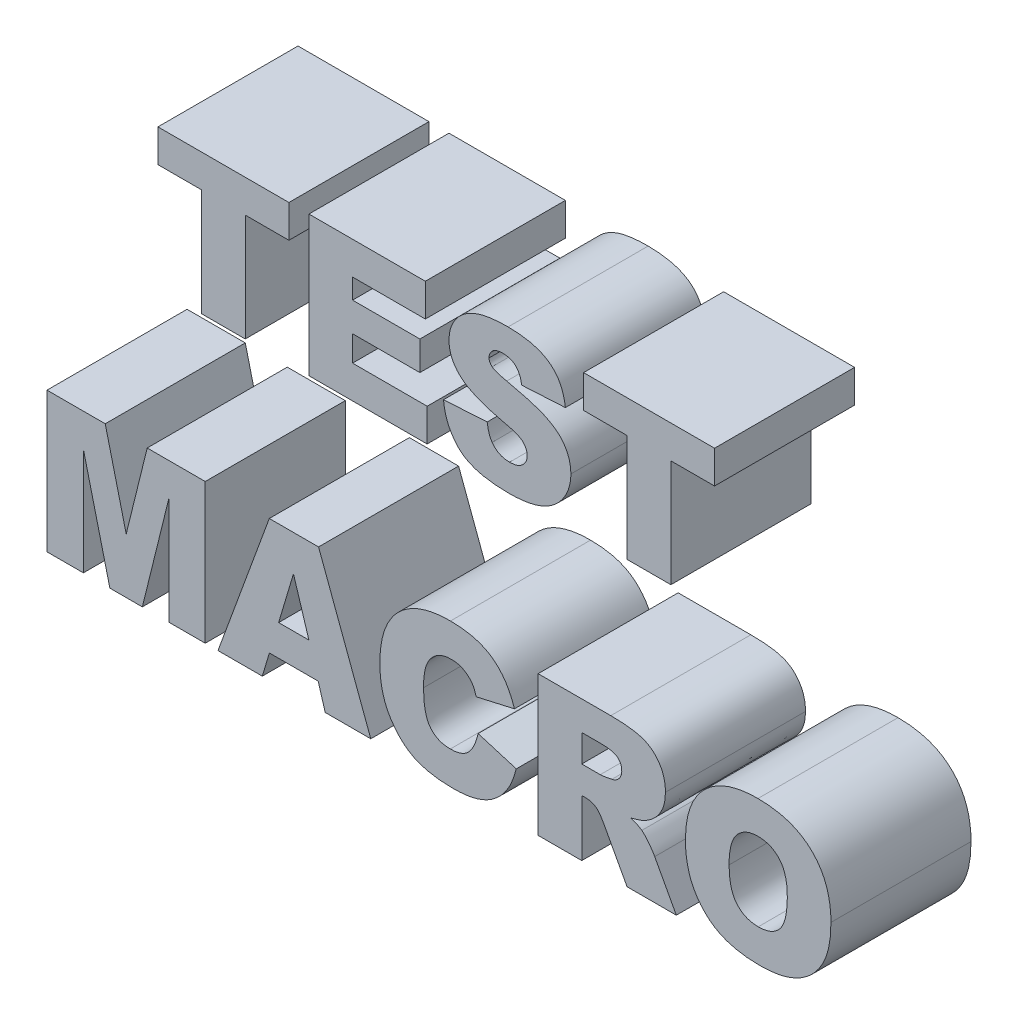
from build123d import *

# Parameters (mm, degrees)
BOSS_EXTRU_1_DEPTH   = 20
BOSS_EXTRU_1_2_DEPTH = 20
BOSS_EXTRU_1_3_DEPTH = 20
BOSS_EXTRU_1_4_DEPTH = 20
BOSS_EXTRU_1_5_DEPTH = 20
BOSS_EXTRU_1_6_DEPTH = 20
BOSS_EXTRU_1_7_DEPTH = 20
BOSS_EXTRU_1_8_DEPTH = 20
BOSS_EXTRU_1_9_DEPTH = 20


with BuildPart() as part:
    # Esquisse1 → Boss.-Extru.1 (new body)
    with BuildSketch(Plane.XY):
        Polygon((-39.74025974, 20), (-21.038961039, 20), (-21.038961039, 15.324675325), (-27.272727273, 15.324675325), (-27.272727273, 0), (-33.506493506, 0), (-33.506493506, 15.324675325), (-39.74025974, 15.324675325), align=None)
    extrude(amount=BOSS_EXTRU_1_DEPTH)


with BuildPart() as body_2:
    # Esquisse1 → Boss.-Extru.1 2 (new body)
    with BuildSketch(Plane.XY):
        Polygon((-18.181818182, 20), (-1.558441558, 20), (-1.558441558, 15.324675325), (-11.948051948, 15.324675325), (-11.948051948, 12.467532468), (-2.337662338, 12.467532468), (-2.337662338, 8.311688312), (-11.948051948, 8.311688312), (-11.948051948, 4.675324675), (-1.298701299, 4.675324675), (-1.298701299, 0), (-18.181818182, 0), align=None)
    extrude(amount=BOSS_EXTRU_1_2_DEPTH)


with BuildPart() as body_3:
    # Esquisse1 → Boss.-Extru.1 3 (new body)
    with BuildSketch(Plane.XY):
        with BuildLine():
            Line((1.038961039, 6.647727273), (7.272727273, 7.012987013))
            add(Edge.make_bspline(
                [(7.272727273, 7.012987013), (7.304757488, 6.788890935), (7.365318812, 6.365179916), (7.520102948, 5.775721889), (7.715213941, 5.266442228), (7.897409487, 4.977422352), (7.982954545, 4.841720779)],
                knots=[0, 0, 0, 0, 1.177086864, 2.225584133, 3.166870363, 4, 4, 4, 4], degree=3))
            add(Edge.make_bspline(
                [(7.982954545, 4.841720779), (8.057748183, 4.745013581), (8.204026944, 4.55587705), (8.460115533, 4.309854222), (8.737918662, 4.100984335), (9.038994512, 3.929550021), (9.364258811, 3.798854044), (9.711720263, 3.706001839), (10.083305918, 3.648068474), (10.339339805, 3.640334173), (10.470779221, 3.636363636)],
                knots=[0, 0, 0, 0, 1.018395363, 1.991741784, 2.950663557, 3.910580234, 4.872152798, 5.865559653, 6.904248207, 8, 8, 8, 8], degree=3))
            add(Edge.make_bspline(
                [(10.470779221, 3.636363636), (10.660697178, 3.644207006), (11.022625097, 3.659154168), (11.533809901, 3.769484502), (11.973966232, 3.967441181), (12.340863101, 4.236798571), (12.620513949, 4.563886639), (12.837407106, 4.912793324), (12.963617859, 5.29468435), (12.979194665, 5.557847844), (12.987012987, 5.689935065)],
                knots=[0, 0, 0, 0, 1.255494896, 2.392604995, 3.433462242, 4.424586182, 5.375455995, 6.262142744, 7.127733362, 8, 8, 8, 8], degree=3))
            add(Edge.make_bspline(
                [(12.987012987, 5.689935065), (12.979878177, 5.816517585), (12.965736379, 6.067414854), (12.854878841, 6.431888084), (12.674125852, 6.77522457), (12.505409594, 6.97526787), (12.418831169, 7.077922078)],
                knots=[0, 0, 0, 0, 0.988314839, 1.958923673, 2.95260139, 4, 4, 4, 4], degree=3))
            add(Edge.make_bspline(
                [(12.418831169, 7.077922078), (12.363439884, 7.129790582), (12.240799231, 7.244631523), (12.003357878, 7.390373942), (11.710911221, 7.540678866), (11.35684867, 7.684129653), (10.944336218, 7.825116295), (10.473595352, 7.967349697), (9.940841737, 8.10371271), (9.564606885, 8.189495991), (9.366883117, 8.234577922)],
                knots=[0, 0, 0, 0, 0.55123045, 1.220467485, 2.017678126, 2.944918583, 3.99760765, 5.190855943, 6.523702564, 8, 8, 8, 8], degree=3))
            add(Edge.make_bspline(
                [(9.366883117, 8.234577922), (9.038755531, 8.310107225), (8.405080772, 8.455968211), (7.497896672, 8.715197767), (6.661730047, 8.98259304), (5.899095569, 9.275803812), (5.208846498, 9.586729824), (4.590906008, 9.914158894), (4.043015356, 10.257363012), (3.722047871, 10.516400681), (3.56737013, 10.641233766)],
                knots=[0, 0, 0, 0, 1.27526578, 2.462772933, 3.57286582, 4.599737504, 5.556111329, 6.438742692, 7.247613029, 8, 8, 8, 8], degree=3))
            add(Edge.make_bspline(
                [(3.56737013, 10.641233766), (3.427977592, 10.768351486), (3.153824483, 11.018362847), (2.79600712, 11.435004806), (2.491087609, 11.87585656), (2.24897906, 12.345217097), (2.054206783, 12.838127189), (1.91786419, 13.35708603), (1.83454926, 13.90288953), (1.823712326, 14.274591676), (1.818181818, 14.464285714)],
                knots=[0, 0, 0, 0, 1.041173921, 2.047749992, 3.025972441, 3.99516429, 4.95811478, 5.947685897, 6.952624423, 8, 8, 8, 8], degree=3))
            add(Edge.make_bspline(
                [(1.818181818, 14.464285714), (1.829440042, 14.715442956), (1.851959923, 15.217834042), (2.02443191, 15.957122705), (2.306111483, 16.672945441), (2.62558045, 17.243912502), (2.933739677, 17.68260842), (3.198757164, 17.996149923), (3.493277568, 18.289221073), (3.814866517, 18.565787518), (4.163552599, 18.824505998), (4.539160907, 19.067030798), (4.946029313, 19.282685268), (5.378756053, 19.489381732), (5.847595304, 19.672349396), (6.356395013, 19.82973168), (6.906699601, 19.963584625), (7.497701456, 20.071314884), (8.130126213, 20.156728846), (8.803181667, 20.216124972), (9.517977912, 20.253257532), (10.008069294, 20.257540749), (10.25974026, 20.25974026)],
                knots=[0, 0, 0, 0, 1.30907172, 2.618542707, 3.936691428, 5.31077926, 6.019465884, 6.730466994, 7.448921369, 8.184394082, 8.940790577, 9.711951077, 10.513842775, 11.340797704, 12.212135637, 13.136052958, 14.116643754, 15.164270918, 16.267925536, 17.44397513, 18.687434074, 20, 20, 20, 20], degree=3))
            add(Edge.make_bspline(
                [(10.25974026, 20.25974026), (10.568342802, 20.256941234), (11.166092343, 20.251519646), (12.034296107, 20.178603689), (12.846609378, 20.072531329), (13.602815531, 19.920390908), (14.300635089, 19.719423531), (14.946063298, 19.484031066), (15.531678257, 19.193535604), (16.066217055, 18.864457954), (16.545763364, 18.483061279), (16.975028198, 18.051046223), (17.349291106, 17.564576082), (17.67319508, 17.026717817), (17.943001271, 16.436159553), (18.167136755, 15.795393237), (18.338927282, 15.10235266), (18.406710328, 14.619290084), (18.441558442, 14.370941558)],
                knots=[0, 0, 0, 0, 1.311515668, 2.540348123, 3.700957581, 4.792716183, 5.815693949, 6.78561682, 7.708932939, 8.58979416, 9.449314928, 10.307353016, 11.17237775, 12.052130674, 12.970724468, 13.927412188, 14.934456625, 16, 16, 16, 16], degree=3))
            Line((18.441558442, 14.370941558), (12.207792208, 14.025974026))
            add(Edge.make_bspline(
                [(12.207792208, 14.025974026), (12.168366471, 14.238211159), (12.094144138, 14.637765774), (11.909520247, 15.188415747), (11.658879014, 15.645051097), (11.345852875, 16.012778297), (10.969483014, 16.291833535), (10.529579913, 16.48869648), (10.025790111, 16.600629888), (9.670482334, 16.615563203), (9.484577922, 16.623376623)],
                knots=[0, 0, 0, 0, 1.234522949, 2.324095391, 3.308461247, 4.197778927, 5.06646789, 5.967370861, 6.936486201, 8, 8, 8, 8], degree=3))
            add(Edge.make_bspline(
                [(9.484577922, 16.623376623), (9.332640126, 16.618594079), (9.046327063, 16.609581806), (8.643949905, 16.525419171), (8.301074326, 16.379458324), (8.019810915, 16.17787747), (7.803687171, 15.935639495), (7.642733592, 15.666844213), (7.552700401, 15.368104926), (7.5392742, 15.161540133), (7.532467532, 15.056818182)],
                knots=[0, 0, 0, 0, 1.295349582, 2.44096936, 3.485284873, 4.452772794, 5.368250369, 6.237362108, 7.106397189, 8, 8, 8, 8], degree=3))
            add(Edge.make_bspline(
                [(7.532467532, 15.056818182), (7.537805846, 14.9788347), (7.548530011, 14.822173281), (7.642276312, 14.596708316), (7.784898824, 14.38170238), (7.91764903, 14.262678671), (7.987012987, 14.200487013)],
                knots=[0, 0, 0, 0, 0.931359322, 1.871012551, 2.887572404, 4, 4, 4, 4], degree=3))
            add(Edge.make_bspline(
                [(7.987012987, 14.200487013), (8.029684325, 14.167153327), (8.122118566, 14.094946216), (8.287506403, 13.99681263), (8.492892242, 13.905598235), (8.733985241, 13.813292624), (9.01350503, 13.724155735), (9.329226445, 13.636226954), (9.681888588, 13.545839835), (9.930782476, 13.49334669), (10.060876623, 13.465909091)],
                knots=[0, 0, 0, 0, 0.58558372, 1.268485821, 2.074195609, 3.01489626, 4.061191977, 5.247631417, 6.561366666, 8, 8, 8, 8], degree=3))
            add(Edge.make_bspline(
                [(10.060876623, 13.465909091), (10.387067838, 13.393586512), (11.015988584, 13.254143239), (11.923542647, 13.040566279), (12.757077273, 12.822446725), (13.518675373, 12.60240291), (14.210259261, 12.385724835), (14.827982673, 12.162549099), (15.377180204, 11.945483152), (15.856898714, 11.719139488), (16.288368969, 11.488494744), (16.681667772, 11.244221761), (17.04748109, 10.9898726), (17.383126712, 10.720726157), (17.687089142, 10.436018445), (17.964347685, 10.140664585), (18.210007715, 9.829671477), (18.493887745, 9.399505856), (18.785318282, 8.831220693), (19.040676871, 8.108589725), (19.194603618, 7.344176044), (19.211968142, 6.820238606), (19.220779221, 6.554383117)],
                knots=[0, 0, 0, 0, 1.592169224, 3.069819826, 4.44270182, 5.69748484, 6.847378755, 7.89551184, 8.826870635, 9.660312258, 10.421783, 11.157070095, 11.86529408, 12.543880036, 13.205252394, 13.848401972, 14.47263075, 15.091275346, 16.302236043, 17.505191012, 18.73408805, 20, 20, 20, 20], degree=3))
            add(Edge.make_bspline(
                [(19.220779221, 6.554383117), (19.217646961, 6.395990945), (19.211447687, 6.082505888), (19.162246953, 5.616825519), (19.07596159, 5.161387963), (18.95804342, 4.71380739), (18.8083259, 4.275334519), (18.623924435, 3.8472749), (18.408607586, 3.42730946), (18.158636428, 3.020450719), (17.877153681, 2.631625875), (17.575426862, 2.259755875), (17.23791471, 1.920264518), (16.882949454, 1.594601112), (16.489702368, 1.307629517), (16.081078883, 1.030409462), (15.638277087, 0.789487484), (15.172913565, 0.563679022), (14.67511286, 0.370970487), (14.150290205, 0.198281994), (13.59226252, 0.058621134), (13.003476069, -0.060367264), (12.382530041, -0.147323407), (11.731323148, -0.211877842), (11.050341943, -0.25416091), (10.58583241, -0.257856336), (10.349025974, -0.25974026)],
                knots=[0, 0, 0, 0, 0.906069916, 1.793266525, 2.675214908, 3.55566777, 4.439244741, 5.323397786, 6.219930383, 7.137170545, 8.052187568, 8.964877591, 9.873423338, 10.788702187, 11.717462046, 12.655527384, 13.611744184, 14.598361818, 15.613055283, 16.663057224, 17.757447019, 18.901923475, 20.098271487, 21.342794296, 22.645359534, 24, 24, 24, 24], degree=3))
            add(Edge.make_bspline(
                [(10.349025974, -0.25974026), (9.938987085, -0.253136013), (9.150347592, -0.240433877), (8.016453658, -0.154700187), (6.982252, 0.000180008), (6.04322188, 0.205183493), (5.203695963, 0.482027844), (4.456483235, 0.811678702), (3.80896829, 1.209064881), (3.261695195, 1.673654588), (2.793442085, 2.182247392), (2.384581172, 2.725367656), (2.017822275, 3.294409019), (1.714772738, 3.902768442), (1.462240866, 4.542339722), (1.262591013, 5.21419737), (1.120595321, 5.919615671), (1.066471538, 6.40235593), (1.038961039, 6.647727273)],
                knots=[0, 0, 0, 0, 1.505803467, 2.896154762, 4.172048974, 5.343508697, 6.421214708, 7.412908531, 8.336567115, 9.200370628, 10.040536338, 10.870193375, 11.694343728, 12.523048299, 13.361626238, 14.216714319, 15.093576323, 16, 16, 16, 16], degree=3))
        make_face()
    extrude(amount=BOSS_EXTRU_1_3_DEPTH)


with BuildPart() as body_4:
    # Esquisse1 → Boss.-Extru.1 4 (new body)
    with BuildSketch(Plane.XY):
        Polygon((21.038961039, 20), (39.74025974, 20), (39.74025974, 15.324675325), (33.506493506, 15.324675325), (33.506493506, 0), (27.272727273, 0), (27.272727273, 15.324675325), (21.038961039, 15.324675325), align=None)
    extrude(amount=BOSS_EXTRU_1_4_DEPTH)


with BuildPart() as body_5:
    # Esquisse1 → Boss.-Extru.1 5 (new body)
    with BuildSketch(Plane.XY):
        Polygon((-55.584415584, -20.480519481), (-47.268668831, -20.480519481), (-44.273538961, -32.619318182), (-41.274350649, -20.480519481), (-32.987012987, -20.480519481), (-32.987012987, -40.480519481), (-38.181818182, -40.480519481), (-38.181818182, -25.168019481), (-41.968344156, -40.480519481), (-46.607142857, -40.480519481), (-50.38961039, -25.168019481), (-50.38961039, -40.480519481), (-55.584415584, -40.480519481), align=None)
    extrude(amount=BOSS_EXTRU_1_5_DEPTH)


with BuildPart() as body_6:
    # Esquisse1 → Boss.-Extru.1 6 (new body)
    with BuildSketch(Plane.XY):
        Polygon((-16.862824675, -37.103896104), (-23.82711039, -37.103896104), (-24.837662338, -40.480519481), (-31.168831169, -40.480519481), (-23.839285714, -20.480519481), (-16.806006494, -20.480519481), (-9.350649351, -40.480519481), (-15.852272727, -40.480519481), align=None)
        Polygon((-18.185876623, -32.688311688), (-20.38961039, -25.594155844), (-22.508116883, -32.688311688), align=None, mode=Mode.SUBTRACT)
    extrude(amount=BOSS_EXTRU_1_6_DEPTH)


with BuildPart() as body_7:
    # Esquisse1 → Boss.-Extru.1 7 (new body)
    with BuildSketch(Plane.XY):
        with BuildLine():
            Line((5.974025974, -32.168831169), (11.428571429, -33.808441558))
            add(Edge.make_bspline(
                [(11.428571429, -33.808441558), (11.381594362, -33.99560524), (11.288774064, -34.365415236), (11.121587416, -34.904251888), (10.937129606, -35.419975314), (10.725445525, -35.909062427), (10.507763121, -36.380598058), (10.256877371, -36.82214894), (9.992893827, -37.243025486), (9.618697229, -37.767891947), (9.099132289, -38.367897894), (8.403349708, -39.00164922), (7.631847889, -39.537594215), (6.933478148, -39.904511208), (6.335543565, -40.147156216), (5.853523203, -40.304357233), (5.344867336, -40.443075678), (4.803704413, -40.552143358), (4.234621495, -40.635981389), (3.634725857, -40.696672874), (3.006421009, -40.733598253), (2.577161587, -40.738007897), (2.357954545, -40.74025974)],
                knots=[0, 0, 0, 0, 0.924244921, 1.826182348, 2.701535968, 3.546520642, 4.378482427, 5.187954248, 5.977251764, 6.757720469, 8.273918964, 9.769591919, 11.254542257, 12.76187881, 13.538084839, 14.343473581, 15.189228286, 16.062372142, 16.986208014, 17.943795036, 18.949971547, 20, 20, 20, 20], degree=3))
            add(Edge.make_bspline(
                [(2.357954545, -40.74025974), (2.091405499, -40.736560624), (1.571528512, -40.729345872), (0.81037975, -40.690137052), (0.086853014, -40.6184521), (-0.599029501, -40.510691529), (-1.250548636, -40.384277359), (-1.862927904, -40.221617649), (-2.437761763, -40.030769844), (-2.978673964, -39.811074509), (-3.493484538, -39.553421284), (-3.982720164, -39.247233538), (-4.45815626, -38.900936829), (-4.910733261, -38.505037026), (-5.350794823, -38.069440668), (-5.774982974, -37.58995615), (-6.173236365, -37.059732254), (-6.561549698, -36.494198062), (-6.914902875, -35.88319584), (-7.220535059, -35.225978334), (-7.474567144, -34.525689779), (-7.684651118, -33.786292865), (-7.852582222, -33.007127393), (-7.968527518, -32.18525913), (-8.037495462, -31.321806784), (-8.047068979, -30.732270845), (-8.051948052, -30.431818182)],
                knots=[0, 0, 0, 0, 1.147650446, 2.238376252, 3.280413316, 4.276323793, 5.226689047, 6.13651372, 7.002182501, 7.832854118, 8.648150377, 9.477309563, 10.314915342, 11.177895551, 12.063382281, 12.979505193, 13.931243744, 14.916675708, 15.931699666, 16.966189071, 18.033078903, 19.13554484, 20.273354093, 21.461953011, 22.706502983, 24, 24, 24, 24], degree=3))
            add(Edge.make_bspline(
                [(-8.051948052, -30.431818182), (-8.045127637, -30.033702385), (-8.031844806, -29.258367586), (-7.900827666, -28.131177473), (-7.703502588, -27.071945005), (-7.415838523, -26.083976506), (-7.040468271, -25.171169768), (-6.589262006, -24.326086781), (-6.049371871, -23.555231015), (-5.43126086, -22.853934719), (-4.735711713, -22.232402228), (-3.970049566, -21.692496225), (-3.135509323, -21.235273882), (-2.232698525, -20.863316896), (-1.2615876, -20.57402325), (-0.223348382, -20.370498446), (0.8828391, -20.241382625), (1.643297667, -20.227763459), (2.033279221, -20.220779221)],
                knots=[0, 0, 0, 0, 1.16882947, 2.276307973, 3.328298317, 4.330369038, 5.292534416, 6.222298076, 7.138273771, 8.050302673, 8.962002626, 9.87147472, 10.796156015, 11.750975379, 12.733998957, 13.767258903, 14.854996341, 16, 16, 16, 16], degree=3))
            add(Edge.make_bspline(
                [(2.033279221, -20.220779221), (2.33915563, -20.225263769), (2.935587602, -20.234008241), (3.80463555, -20.307316386), (4.622940972, -20.429837288), (5.392636217, -20.591540902), (6.109043783, -20.813988319), (6.779816192, -21.0749233), (7.396891332, -21.392981049), (7.968869526, -21.756971), (8.493499483, -22.174802293), (8.984423343, -22.638896706), (9.434864273, -23.160067609), (9.859383323, -23.726491921), (10.239534428, -24.352898573), (10.588368256, -25.026576584), (10.902697676, -25.752294683), (11.078768789, -26.259856743), (11.168831169, -26.519480519)],
                knots=[0, 0, 0, 0, 1.217751659, 2.374508141, 3.469163924, 4.51086882, 5.502490221, 6.452709996, 7.372946509, 8.261977267, 9.147787688, 10.039327766, 10.947855999, 11.887251211, 12.85447837, 13.861487269, 14.906126374, 16, 16, 16, 16], degree=3))
            Line((11.168831169, -26.519480519), (5.714285714, -27.753246753))
            add(Edge.make_bspline(
                [(5.714285714, -27.753246753), (5.668858206, -27.607812612), (5.583941635, -27.335956002), (5.436691359, -26.964938693), (5.290886402, -26.652432483), (5.175004097, -26.47513946), (5.121753247, -26.393668831)],
                knots=[0, 0, 0, 0, 1.227562621, 2.294653845, 3.216350308, 4, 4, 4, 4], degree=3))
            add(Edge.make_bspline(
                [(5.121753247, -26.393668831), (5.033940652, -26.277612381), (4.861176328, -26.049280507), (4.555803565, -25.751855445), (4.225481079, -25.493780994), (3.867229538, -25.278240613), (3.483579991, -25.105654405), (3.075408373, -24.98498723), (2.646197399, -24.909401982), (2.352860428, -24.900585845), (2.203733766, -24.896103896)],
                knots=[0, 0, 0, 0, 1.022346025, 2.011384825, 2.987756405, 3.965193716, 4.94480522, 5.938182432, 6.9518131, 8, 8, 8, 8], degree=3))
            add(Edge.make_bspline(
                [(2.203733766, -24.896103896), (2.035676419, -24.900258937), (1.707159303, -24.908381178), (1.230050481, -24.986982879), (0.782408797, -25.116690392), (0.366094472, -25.301742738), (-0.023407041, -25.533134156), (-0.378953168, -25.820852256), (-0.702298649, -26.160437547), (-0.88764181, -26.417050291), (-0.982142857, -26.54788961)],
                knots=[0, 0, 0, 0, 1.074844658, 2.101097481, 3.084644682, 4.049882427, 5.009082629, 5.975872329, 6.967956603, 8, 8, 8, 8], degree=3))
            add(Edge.make_bspline(
                [(-0.982142857, -26.54788961), (-1.049663799, -26.656070598), (-1.189710868, -26.880451801), (-1.355469296, -27.257128679), (-1.505227707, -27.6721141), (-1.613105213, -28.134807819), (-1.709349176, -28.637887494), (-1.770389013, -29.187406731), (-1.81304989, -29.779080125), (-1.816435026, -30.188224679), (-1.818181818, -30.399350649)],
                knots=[0, 0, 0, 0, 0.765245572, 1.587217177, 2.466349779, 3.412541567, 4.437552015, 5.542455106, 6.731862501, 8, 8, 8, 8], degree=3))
            add(Edge.make_bspline(
                [(-1.818181818, -30.399350649), (-1.814825214, -30.660490254), (-1.808402351, -31.160180961), (-1.766676669, -31.878605152), (-1.684622911, -32.532815731), (-1.577465298, -33.124235791), (-1.442521854, -33.654388989), (-1.267602658, -34.117381784), (-1.067558141, -34.521417882), (-0.826667912, -34.860050154), (-0.559628516, -35.146626957), (-0.268408779, -35.393986876), (0.049417998, -35.599431346), (0.389166806, -35.774130257), (0.758454914, -35.902798294), (1.151685086, -35.994714627), (1.570233085, -36.053423749), (1.857213247, -36.061024388), (2.00487013, -36.064935065)],
                knots=[0, 0, 0, 0, 1.602188715, 3.065788552, 4.412313171, 5.644618019, 6.751844607, 7.7630822, 8.676201586, 9.50981682, 10.302645847, 11.074162151, 11.847640242, 12.619692074, 13.412477657, 14.239872104, 15.094379917, 16, 16, 16, 16], degree=3))
            add(Edge.make_bspline(
                [(2.00487013, -36.064935065), (2.146998792, -36.061466565), (2.423861415, -36.054710026), (2.826689187, -36.012557164), (3.201147249, -35.92994323), (3.548981488, -35.820080839), (3.871765131, -35.683458782), (4.166468548, -35.511879273), (4.433195239, -35.306581732), (4.672752057, -35.068360652), (4.893316179, -34.803568328), (5.091650709, -34.507600587), (5.27832726, -34.186147091), (5.452882131, -33.838830351), (5.608050882, -33.461447212), (5.742680797, -33.056145727), (5.871988025, -32.624061236), (5.939350952, -32.32352962), (5.974025974, -32.168831169)],
                knots=[0, 0, 0, 0, 1.110419556, 2.163065953, 3.158007967, 4.100495665, 5.00938437, 5.890256362, 6.756877028, 7.631195438, 8.524217963, 9.444584223, 10.410653115, 11.426752889, 12.478656378, 13.594843866, 14.761947466, 16, 16, 16, 16], degree=3))
        make_face()
    extrude(amount=BOSS_EXTRU_1_7_DEPTH)


with BuildPart() as body_8:
    # Esquisse1 → Boss.-Extru.1 8 (new body)
    with BuildSketch(Plane.XY):
        with BuildLine():
            Line((14.545454545, -40.480519481), (14.545454545, -20.480519481))
            Line((14.545454545, -20.480519481), (24.92288961, -20.480519481))
            add(Edge.make_bspline(
                [(24.92288961, -20.480519481), (25.156953806, -20.481870004), (25.610335127, -20.484485963), (26.26791653, -20.510420417), (26.882439649, -20.545468034), (27.455470981, -20.596168908), (27.985755772, -20.670303345), (28.473107774, -20.755137059), (28.918973463, -20.849350527), (29.324335183, -20.970436328), (29.703478037, -21.10281061), (30.058267017, -21.265638693), (30.392213467, -21.460013947), (30.71262198, -21.671568877), (31.011372515, -21.914995519), (31.292619135, -22.182250911), (31.551238278, -22.481027772), (31.794658275, -22.799543121), (32.014669833, -23.140764093), (32.205431267, -23.503546672), (32.368803793, -23.884413422), (32.496220418, -24.2850903), (32.604828876, -24.700095653), (32.676899237, -25.13610385), (32.71610348, -25.590722567), (32.723510495, -25.899819263), (32.727272727, -26.056818182)],
                knots=[0, 0, 0, 0, 1.530161939, 2.963916964, 4.301772633, 5.554104584, 6.723590755, 7.801032641, 8.78815049, 9.700526589, 10.564961228, 11.411843923, 12.247756654, 13.089125762, 13.919263632, 14.763741457, 15.622365315, 16.499733513, 17.382922017, 18.273079804, 19.176582198, 20.088357964, 21.01932039, 21.978954871, 22.973454249, 24, 24, 24, 24], degree=3))
            add(Edge.make_bspline(
                [(32.727272727, -26.056818182), (32.719564812, -26.325323939), (32.704545714, -26.848515236), (32.563020941, -27.60324388), (32.336480566, -28.304179975), (32.012728178, -28.942893126), (31.611098398, -29.523456304), (31.140108422, -30.046279314), (30.601748565, -30.515562931), (30.197090132, -30.772368368), (29.991883117, -30.902597403)],
                knots=[0, 0, 0, 0, 1.101993432, 2.147266335, 3.141901439, 4.118584363, 5.077365473, 6.033582582, 7.002806774, 8, 8, 8, 8], degree=3))
            add(Edge.make_bspline(
                [(29.991883117, -30.902597403), (29.845713872, -30.981031733), (29.534749401, -31.147895084), (29.012251081, -31.355527276), (28.413975841, -31.539810774), (27.987637851, -31.64357361), (27.763798701, -31.698051948)],
                knots=[0, 0, 0, 0, 0.837915425, 1.782604315, 2.835806388, 4, 4, 4, 4], degree=3))
            add(Edge.make_bspline(
                [(27.763798701, -31.698051948), (27.9349973, -31.758337299), (28.25484777, -31.870968464), (28.692236757, -32.057368788), (29.055763978, -32.24483425), (29.26377241, -32.384898662), (29.358766234, -32.448863636)],
                knots=[0, 0, 0, 0, 1.231012792, 2.299902127, 3.223594947, 4, 4, 4, 4], degree=3))
            add(Edge.make_bspline(
                [(29.358766234, -32.448863636), (29.421982867, -32.500535919), (29.568960175, -32.620672859), (29.792631577, -32.855963326), (30.054921224, -33.160641109), (30.339135243, -33.517444119), (30.6219478, -33.882136869), (30.865352581, -34.221157855), (31.055665915, -34.512814019), (31.153648502, -34.696630462), (31.19724026, -34.778409091)],
                knots=[0, 0, 0, 0, 0.656872418, 1.527214186, 2.608218659, 3.894218048, 5.199173982, 6.323536816, 7.254153438, 8, 8, 8, 8], degree=3))
            Line((31.19724026, -34.778409091), (34.285714286, -40.480519481))
            Line((34.285714286, -40.480519481), (27.252435065, -40.480519481))
            Line((27.252435065, -40.480519481), (23.965097403, -34.417207792))
            add(Edge.make_bspline(
                [(23.965097403, -34.417207792), (23.86631295, -34.236969623), (23.683973414, -33.904280183), (23.395037198, -33.46935105), (23.131194857, -33.125233215), (22.93286822, -32.960283133), (22.844967532, -32.887175325)],
                knots=[0, 0, 0, 0, 1.29093653, 2.38285239, 3.283261246, 4, 4, 4, 4], degree=3))
            add(Edge.make_bspline(
                [(22.844967532, -32.887175325), (22.731842272, -32.817327224), (22.505880043, -32.677809026), (22.133113285, -32.53231264), (21.737102225, -32.444007207), (21.465566373, -32.433784157), (21.32711039, -32.428571429)],
                knots=[0, 0, 0, 0, 0.98982165, 1.977120801, 2.968535002, 4, 4, 4, 4], degree=3))
            Line((21.32711039, -32.428571429), (20.779220779, -32.428571429))
            Line((20.779220779, -32.428571429), (20.779220779, -40.480519481))
            Line((20.779220779, -40.480519481), (14.545454545, -40.480519481))
        make_face()
        with BuildLine():
            Line((20.779220779, -28.532467532), (23.421266234, -28.532467532))
            add(Edge.make_bspline(
                [(23.421266234, -28.532467532), (23.509312392, -28.528299319), (23.720115267, -28.518319653), (24.085325977, -28.463489036), (24.550876451, -28.382941434), (24.893336402, -28.311765725), (25.081168831, -28.272727273)],
                knots=[0, 0, 0, 0, 0.628542805, 1.504876911, 2.631474917, 4, 4, 4, 4], degree=3))
            add(Edge.make_bspline(
                [(25.081168831, -28.272727273), (25.18117077, -28.249402801), (25.379271353, -28.203197783), (25.651293318, -28.069521602), (25.897794386, -27.896567454), (26.10649029, -27.677400099), (26.276376304, -27.425579024), (26.403837618, -27.153765464), (26.480319612, -26.861795141), (26.48905241, -26.661979211), (26.493506494, -26.560064935)],
                knots=[0, 0, 0, 0, 1.020158048, 2.02089986, 2.99701443, 4.007421106, 5.016748479, 6.011755855, 6.985914375, 8, 8, 8, 8], degree=3))
            add(Edge.make_bspline(
                [(26.493506494, -26.560064935), (26.485787281, -26.413260795), (26.471087624, -26.133702435), (26.357489905, -25.737120018), (26.151105867, -25.401739778), (25.920835577, -25.166442832), (25.694323108, -25.008784517), (25.484276941, -24.90854691), (25.241444706, -24.825233594), (24.964195724, -24.756680316), (24.655473508, -24.69939116), (24.310596939, -24.666277102), (23.933032225, -24.640023927), (23.668887809, -24.637619964), (23.530844156, -24.636363636)],
                knots=[0, 0, 0, 0, 1.307875681, 2.490580844, 3.632121613, 4.783239074, 5.398689137, 6.08357963, 6.850117088, 7.683629419, 8.627346907, 9.646048077, 10.76980885, 12, 12, 12, 12], degree=3))
            Line((23.530844156, -24.636363636), (20.779220779, -24.636363636))
            Line((20.779220779, -24.636363636), (20.779220779, -28.532467532))
        make_face(mode=Mode.SUBTRACT)
    extrude(amount=BOSS_EXTRU_1_8_DEPTH)


with BuildPart() as body_9:
    # Esquisse1 → Boss.-Extru.1 9 (new body)
    with BuildSketch(Plane.XY):
        with BuildLine():
            add(Edge.make_bspline(
                [(35.584415584, -30.492694805), (35.593264074, -30.098700474), (35.610491301, -29.331628339), (35.736187165, -28.213622691), (35.950541021, -27.162118646), (36.250039019, -26.17784222), (36.632011212, -25.258971495), (37.106126708, -24.410456319), (37.664029695, -23.626552809), (38.306973744, -22.914314152), (39.028081285, -22.281619738), (39.814165791, -21.723692636), (40.674960804, -21.261113587), (41.59940057, -20.878662919), (42.590966312, -20.58242121), (43.64835716, -20.374854621), (44.771954155, -20.240100929), (45.544778152, -20.227333979), (45.941558442, -20.220779221)],
                knots=[0, 0, 0, 0, 1.141509498, 2.222418089, 3.254874486, 4.246852721, 5.199093221, 6.132658289, 7.057234514, 7.981445045, 8.906287139, 9.831793572, 10.768447856, 11.731542758, 12.726135355, 13.761653047, 14.850796617, 16, 16, 16, 16], degree=3))
            add(Edge.make_bspline(
                [(45.941558442, -20.220779221), (46.346410673, -20.227738543), (47.135182312, -20.241297356), (48.281815538, -20.370420941), (49.359546855, -20.573861956), (50.364207272, -20.865447518), (51.298331111, -21.239587936), (52.158496722, -21.699654528), (52.94932495, -22.242836276), (53.663594989, -22.869954719), (54.303373843, -23.567628984), (54.854953952, -24.339011663), (55.323353222, -25.174539462), (55.70627617, -26.078309163), (56.002018519, -27.048503522), (56.209250938, -28.084411311), (56.344412327, -29.185014954), (56.357112612, -29.941680812), (56.363636364, -30.330357143)],
                knots=[0, 0, 0, 0, 1.176285812, 2.291751944, 3.348956565, 4.360547542, 5.327243456, 6.268348987, 7.189933859, 8.109453091, 9.025105683, 9.935135631, 10.859333698, 11.803612512, 12.782426517, 13.801834825, 14.870869136, 16, 16, 16, 16], degree=3))
            add(Edge.make_bspline(
                [(56.363636364, -30.330357143), (56.359107551, -30.613159319), (56.350237043, -31.167079106), (56.299470127, -31.978812292), (56.205233306, -32.752173407), (56.076908745, -33.48690658), (55.910680236, -34.182357038), (55.708889239, -34.839748588), (55.464199246, -35.455597561), (55.188939097, -36.036249335), (54.872720529, -36.577784045), (54.528998266, -37.090466434), (54.14907467, -37.570872699), (53.739320657, -38.022203946), (53.295604893, -38.443111263), (52.814399128, -38.826268078), (52.306213571, -39.187165713), (51.761900868, -39.511091053), (51.183932827, -39.799688166), (50.572287686, -40.051950861), (49.925828282, -40.26758686), (49.243383018, -40.441215006), (48.527218554, -40.573476898), (47.778239639, -40.671744151), (46.993562212, -40.728026266), (46.458421763, -40.736123543), (46.185064935, -40.74025974)],
                knots=[0, 0, 0, 0, 1.227170581, 2.403638027, 3.527070403, 4.606008098, 5.638218407, 6.627805636, 7.587035219, 8.511212203, 9.413314863, 10.305489339, 11.187409042, 12.068331905, 12.948628724, 13.83786319, 14.735197904, 15.651286311, 16.583204429, 17.535946325, 18.519754154, 19.537695563, 20.588810062, 21.678029867, 22.813906909, 24, 24, 24, 24], degree=3))
            add(Edge.make_bspline(
                [(46.185064935, -40.74025974), (45.909030427, -40.737130077), (45.367340761, -40.730988432), (44.573447636, -40.683293974), (43.815216465, -40.597005009), (43.094197578, -40.481264694), (42.408719352, -40.330261927), (41.760260806, -40.149483392), (41.146907172, -39.933717116), (40.56870112, -39.682064776), (40.022509156, -39.392153346), (39.504141584, -39.067277159), (39.015250254, -38.699422714), (38.552545147, -38.292501483), (38.113607086, -37.848739356), (37.697628809, -37.369268161), (37.311764992, -36.847797536), (36.955551721, -36.287559038), (36.628752596, -35.692094706), (36.348843391, -35.05633657), (36.113648479, -34.382766624), (35.919746582, -33.674924312), (35.769809732, -32.930302997), (35.660724059, -32.151198242), (35.594633891, -31.333944851), (35.587867833, -30.776910649), (35.584415584, -30.492694805)],
                knots=[0, 0, 0, 0, 1.182354409, 2.320250355, 3.40492002, 4.449983545, 5.446830611, 6.40996121, 7.331835134, 8.229702173, 9.108460858, 9.978232002, 10.847443168, 11.726182747, 12.615349847, 13.519180865, 14.44287423, 15.391301828, 16.361103301, 17.349561128, 18.363044616, 19.41457859, 20.490794782, 21.614332173, 22.782759491, 24, 24, 24, 24], degree=3))
        make_face()
        with BuildLine():
            add(Edge.make_bspline(
                [(41.818181818, -30.492694805), (41.820771943, -30.732244402), (41.825768871, -31.194388958), (41.878570927, -31.861359566), (41.966911582, -32.475549306), (42.088133279, -33.037184826), (42.238472802, -33.549212885), (42.436236013, -34.005814635), (42.660249468, -34.414339001), (42.924492239, -34.768916403), (43.219138134, -35.073616878), (43.537504958, -35.341189938), (43.884530183, -35.56456142), (44.256188938, -35.748383827), (44.652514177, -35.890891632), (45.073004363, -35.991678068), (45.518957368, -36.054178949), (45.825004639, -36.061285994), (45.982142857, -36.064935065)],
                knots=[0, 0, 0, 0, 1.450299893, 2.797951687, 4.047956828, 5.20481418, 6.27504565, 7.273222877, 8.212092413, 9.090248037, 9.941908402, 10.7736376, 11.602983326, 12.434591495, 13.279329446, 14.147571641, 15.048881274, 16, 16, 16, 16], degree=3))
            add(Edge.make_bspline(
                [(45.982142857, -36.064935065), (46.141989097, -36.061279861), (46.454771197, -36.054127473), (46.908410824, -35.991468162), (47.33583915, -35.895073646), (47.735170056, -35.75725041), (48.107256464, -35.577808917), (48.451031794, -35.357352418), (48.764002164, -35.095201255), (49.054120161, -34.795193146), (49.314280836, -34.441704069), (49.531618196, -34.021354344), (49.716407128, -33.5403344), (49.870296194, -32.99850196), (49.985497654, -32.39392656), (50.068814627, -31.726999203), (50.122608447, -30.996819092), (50.127387746, -30.488737084), (50.12987013, -30.224837662)],
                knots=[0, 0, 0, 0, 0.934370097, 1.828346052, 2.672744414, 3.493386017, 4.293052863, 5.083073669, 5.875191127, 6.675327445, 7.518724566, 8.431784964, 9.4337431, 10.528049476, 11.721186616, 13.029232024, 14.4569736, 16, 16, 16, 16], degree=3))
            add(Edge.make_bspline(
                [(50.12987013, -30.224837662), (50.127272946, -30.001510551), (50.122243816, -29.569064896), (50.069066694, -28.944026466), (49.982045082, -28.365730243), (49.855352018, -27.835461437), (49.698848161, -27.349310169), (49.505040385, -26.908676879), (49.273086361, -26.516365176), (49.006126297, -26.17105759), (48.70862198, -25.870646006), (48.386343037, -25.608973106), (48.038472296, -25.38653255), (47.663160209, -25.21086248), (47.266777021, -25.063724832), (46.840499389, -24.970584713), (46.391264585, -24.906872071), (46.08248734, -24.899736028), (45.925324675, -24.896103896)],
                knots=[0, 0, 0, 0, 1.38661201, 2.685004686, 3.892213591, 5.01499786, 6.067066703, 7.059978219, 7.997949574, 8.890262602, 9.763547239, 10.617710116, 11.463736342, 12.32049816, 13.186844934, 14.083537197, 15.024551178, 16, 16, 16, 16], degree=3))
            add(Edge.make_bspline(
                [(45.925324675, -24.896103896), (45.774941401, -24.899820326), (45.479665043, -24.907117505), (45.047340724, -24.969954196), (44.637192521, -25.069297153), (44.250918596, -25.213613232), (43.887542697, -25.397375139), (43.545060758, -25.621020074), (43.2271438, -25.887270522), (42.931423461, -26.193646759), (42.666459536, -26.548368747), (42.437867729, -26.956775486), (42.244015246, -27.416914305), (42.086662143, -27.931122883), (41.967409265, -28.497846766), (41.878444408, -29.115883721), (41.825814, -29.786960633), (41.82078701, -30.251797362), (41.818181818, -30.492694805)],
                knots=[0, 0, 0, 0, 0.914268536, 1.79515897, 2.651298696, 3.4766355, 4.297241835, 5.123398565, 5.958845572, 6.814312838, 7.707908804, 8.643804449, 9.654011714, 10.739306757, 11.909377048, 13.173112582, 14.534991081, 16, 16, 16, 16], degree=3))
        make_face(mode=Mode.SUBTRACT)
    extrude(amount=BOSS_EXTRU_1_9_DEPTH)


solid = Compound([part.part, body_2.part, body_3.part, body_4.part, body_5.part, body_6.part, body_7.part, body_8.part, body_9.part])
